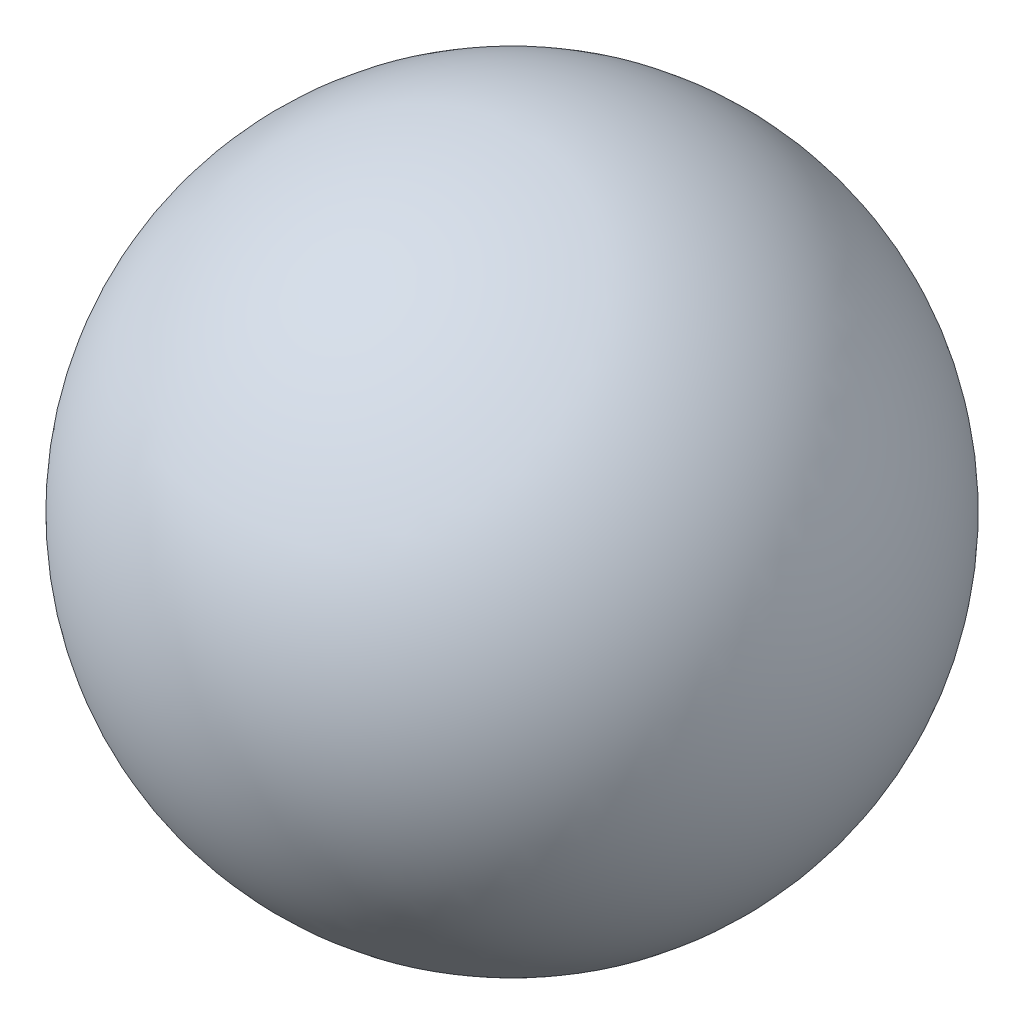
from build123d import *


with BuildPart() as part:
    # Esquisse1 → Révolution1 (revolve)
    with BuildSketch(Plane.XY):
        with BuildLine():
            Line((0, 20), (0, -20))
            ThreePointArc((0, -20), (-20, 0), (0, 20))
        make_face()
    revolve(axis=Axis((0, 20, 0), (0, -1, 0)))


solid = part.part
